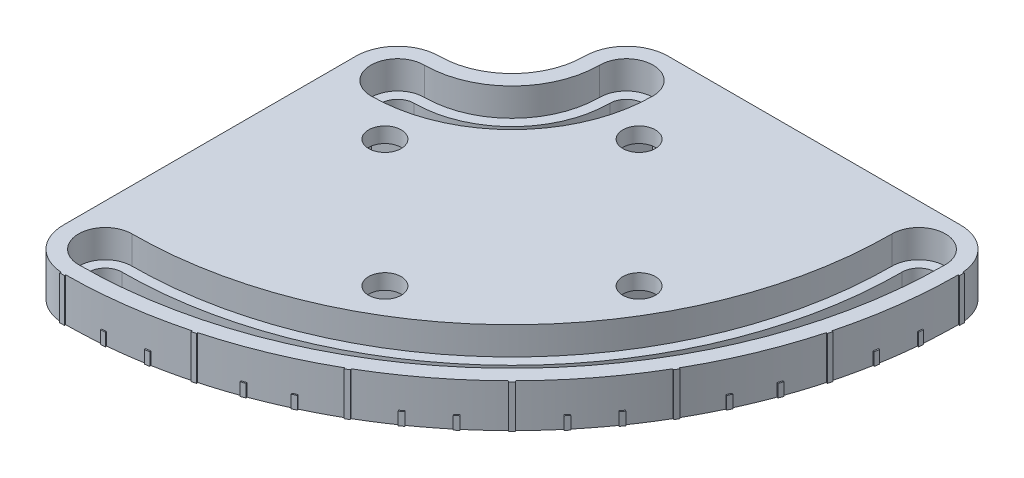
from build123d import *

# Parameters (mm, degrees)
SKETCH_1_R               = 3.2
EXTRUDE_1_DEPTH          = 8.5
EXTRUDE_2_DEPTH          = 8.5
PATTERN_CIRCULAR_1_COUNT = 7
PATTERN_CIRCULAR_1_ANGLE = 90
EXTRUDE_3_DEPTH          = 2.5
PATTERN_CIRCULAR_2_COUNT = 19
PATTERN_CIRCULAR_2_ANGLE = 90
CUT_EXTRUDE_1_DEPTH      = 5.5
CUT_EXTRUDE_2_DEPTH      = 5.5


with BuildPart() as part:
    # 스케치1 → 보스-돌출1 (new body)
    with BuildSketch(Plane(origin=(0, 0, 0), x_dir=(1, 0, 0), z_dir=(0, 1, 0))):
        with BuildLine():
            Line((-8.25, -80), (-8.25, -22.5))
            ThreePointArc((-8.25, -22.5), (-5.833630945, -16.666369055), (0, -14.25))
            ThreePointArc((0, -14.25), (10.076271632, -10.076271632), (14.25, 0))
            ThreePointArc((14.25, 0), (16.666369055, 5.833630945), (22.5, 8.25))
            Line((22.5, 8.25), (80, 8.25))
            ThreePointArc((80, 8.25), (85.833630945, 5.833630945), (88.25, 0))
            ThreePointArc((88.25, 0), (62.40217344, -62.40217344), (0, -88.25))
            ThreePointArc((0, -88.25), (-5.833630945, -85.833630945), (-8.25, -80))
        make_face()
        with Locations((58.75, -33.75)):
            Circle(SKETCH_1_R, mode=Mode.SUBTRACT)
        with Locations((33.75, -58.75)):
            Circle(SKETCH_1_R, mode=Mode.SUBTRACT)
        with Locations((8.75, -33.75)):
            Circle(SKETCH_1_R, mode=Mode.SUBTRACT)
        with Locations((33.75, -8.75)):
            Circle(SKETCH_1_R, mode=Mode.SUBTRACT)
        with BuildLine():
            ThreePointArc((0, -19.25), (-3.25, -22.5), (0, -25.75))
            ThreePointArc((0, -25.75), (18.207999616, -18.207999616), (25.75, 0))
            ThreePointArc((25.75, 0), (22.5, 3.25), (19.25, 0))
            ThreePointArc((19.25, 0), (13.611805538, -13.611805538), (0, -19.25))
        make_face(mode=Mode.SUBTRACT)
        with BuildLine():
            ThreePointArc((0, -76.75), (-3.25, -80), (0, -83.25))
            ThreePointArc((0, -83.25), (58.866639534, -58.866639534), (83.25, 0))
            ThreePointArc((83.25, 0), (80, 3.25), (76.75, 0))
            ThreePointArc((76.75, 0), (54.270445456, -54.270445456), (0, -76.75))
        make_face(mode=Mode.SUBTRACT)
    extrude(amount=EXTRUDE_1_DEPTH)

    # 스케치2 → 보스-돌출2 (add)
    with BuildSketch(Plane(origin=(0, 8.5, 0), x_dir=(1, 0, 0), z_dir=(0, 1, 0))):
        with BuildLine():
            Line((0.458146835, -87.498800572), (0.463382799, -88.498786864))
            ThreePointArc((0.463382799, -88.498786864), (0, -88.5), (-0.463382799, -88.498786864))
            Line((-0.463382799, -88.498786864), (-0.458146835, -87.498800572))
            ThreePointArc((-0.458146835, -87.498800572), (0, -87.5), (0.458146835, -87.498800572))
        make_face()
    extrude_2 = extrude(amount=-EXTRUDE_2_DEPTH)

    # 원형 패턴1: 보스-돌출2 ×7 about axis
    pattern_circular_1_axis = Axis((0, 0, 0), (0, 1, 0))
    for i in range(1, PATTERN_CIRCULAR_1_COUNT):
        add(extrude_2.rotate(pattern_circular_1_axis, i * PATTERN_CIRCULAR_1_ANGLE / (PATTERN_CIRCULAR_1_COUNT - 1)))

    # 스케치6 → 보스-돌출3 (add)
    with BuildSketch(Plane.XZ):
        with BuildLine():
            Line((88.498786864, 0.463382799), (87.998793718, 0.460764817))
            ThreePointArc((87.998793718, 0.460764817), (88, 0), (87.998793718, -0.460764817))
            Line((87.998793718, -0.460764817), (88.498786864, -0.463382799))
            ThreePointArc((88.498786864, -0.463382799), (88.5, 0), (88.498786864, 0.463382799))
        make_face()
    extrude_3 = extrude(amount=-EXTRUDE_3_DEPTH)

    # 원형 패턴2: 보스-돌출3 ×19 about axis
    pattern_circular_2_axis = Axis((0, 8.5, 0), (0, -1, 0))
    for i in range(1, PATTERN_CIRCULAR_2_COUNT):
        add(extrude_3.rotate(pattern_circular_2_axis, i * PATTERN_CIRCULAR_2_ANGLE / (PATTERN_CIRCULAR_2_COUNT - 1)))

    # 스케치7 → 컷-돌출1 (cut)
    with BuildSketch(Plane.XZ):
        Polygon((26.650803984, 56.831298374), (35.668701626, 51.650803984), (40.849196016, 60.668701626), (31.831298374, 65.849196016), align=None)
        Polygon((51.650803984, 35.668701626), (56.831298374, 26.650803984), (65.849196016, 31.831298374), (60.668701626, 40.849196016), align=None)
        Polygon((30.021419355, 2.411412904), (40.088587096, 5.021419355), (37.478580645, 15.088587096), (27.411412904, 12.478580645), align=None)
        Polygon((2.411412904, 30.021419355), (12.478580645, 27.411412904), (15.088587096, 37.478580645), (5.021419355, 40.088587096), align=None)
    extrude(amount=-CUT_EXTRUDE_1_DEPTH, mode=Mode.SUBTRACT)

    # 스케치8 → 컷-돌출2 (cut)
    with BuildSketch(Plane(origin=(0, 8.5, 0), x_dir=(1, 0, 0), z_dir=(0, 1, 0))):
        with BuildLine():
            ThreePointArc((27.75, 0), (22.5, 5.25), (17.25, 0))
            ThreePointArc((17.25, 0), (12.197591975, -12.197591975), (0, -17.25))
            ThreePointArc((0, -17.25), (-5.25, -22.5), (0, -27.75))
            ThreePointArc((0, -27.75), (19.622213178, -19.622213178), (27.75, 0))
        make_face()
        with BuildLine():
            ThreePointArc((85.25, 0), (80, 5.25), (74.75, 0))
            ThreePointArc((74.75, 0), (52.856231894, -52.856231894), (0, -74.75))
            ThreePointArc((0, -74.75), (-5.25, -80), (0, -85.25))
            ThreePointArc((0, -85.25), (60.280853096, -60.280853096), (85.25, 0))
        make_face()
    extrude(amount=-CUT_EXTRUDE_2_DEPTH, mode=Mode.SUBTRACT)


solid = part.part
